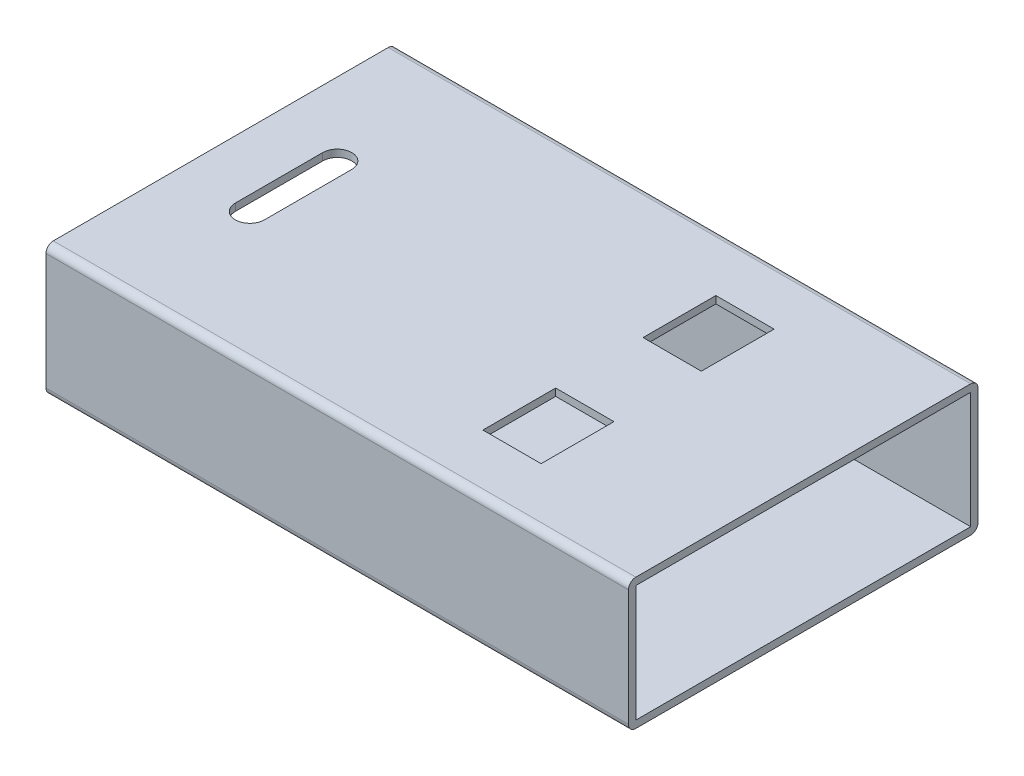
from build123d import *

# Parameters (mm, degrees)
MAIN_SHELL_SKETCH_W     = 11.5
MAIN_SHELL_SKETCH_H     = 4
MAIN_SHELL_DEPTH        = 20
CONNECTOR_HOLE_SKETCH_W = 2
CONNECTOR_HOLE_SKETCH_H = 2.5
CONNECTOR_HOLES_DEPTH   = 5.5


with BuildPart() as part:
    # Main_shell_sketch → Main_shell (new body)
    with BuildSketch(Plane(origin=(0, 0, 0), x_dir=(0, 0, -1), z_dir=(1, 0, 0))):
        with BuildLine():
            Line((-6, 2), (-6, -2))
            ThreePointArc((-6, -2), (-5.926776695, -2.176776695), (-5.75, -2.25))
            Line((-5.75, -2.25), (5.75, -2.25))
            ThreePointArc((5.75, -2.25), (5.926776695, -2.176776695), (6, -2))
            Line((6, -2), (6, 2))
            ThreePointArc((6, 2), (5.926776695, 2.176776695), (5.75, 2.25))
            Line((5.75, 2.25), (-5.75, 2.25))
            ThreePointArc((-5.75, 2.25), (-5.926776695, 2.176776695), (-6, 2))
        make_face()
        Rectangle(MAIN_SHELL_SKETCH_W, MAIN_SHELL_SKETCH_H, mode=Mode.SUBTRACT)
    extrude(amount=-MAIN_SHELL_DEPTH)

    # Connector_hole_sketch → Connector_holes (cut, through all)
    with BuildSketch(Plane(origin=(0, 2.25, 0), x_dir=(1, 0, 0), z_dir=(0, 1, 0))):
        with Locations((-6, 2.75)):
            Rectangle(CONNECTOR_HOLE_SKETCH_W, CONNECTOR_HOLE_SKETCH_H)
        with Locations((-6, -2.75)):
            Rectangle(CONNECTOR_HOLE_SKETCH_W, CONNECTOR_HOLE_SKETCH_H)
        with BuildLine():
            Line((-18, -1.5), (-18, 1.5))
            ThreePointArc((-18, 1.5), (-17.5, 2), (-17, 1.5))
            Line((-17, 1.5), (-17, -1.5))
            ThreePointArc((-17, -1.5), (-17.5, -2), (-18, -1.5))
        make_face()
    extrude(amount=-CONNECTOR_HOLES_DEPTH, mode=Mode.SUBTRACT)


solid = part.part
